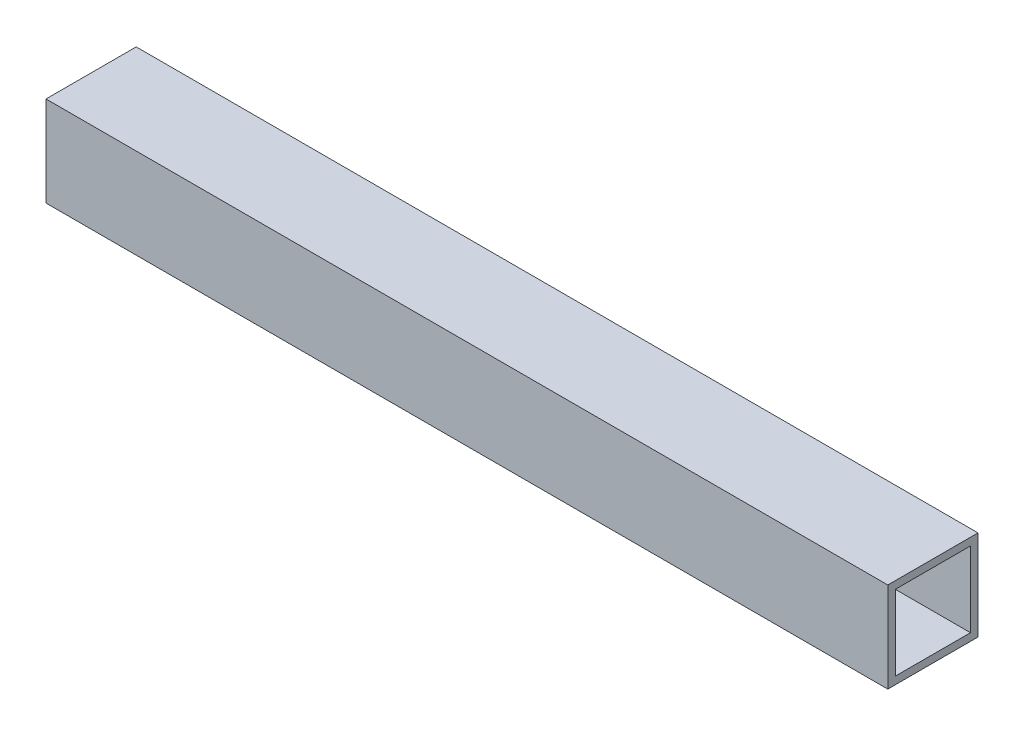
from build123d import *

# Parameters (mm, degrees)
SKETCH1_W           = 19.05
SKETCH1_H           = 19.05
SKETCH1_W_2         = 15.875
SKETCH1_H_2         = 15.875
BOSS_EXTRUDE1_DEPTH = 88.9


with BuildPart() as part:
    # Sketch1 → Boss-Extrude1 (new body, symmetric)
    with BuildSketch(Plane(origin=(0, 0, 0), x_dir=(0, -1, 0), z_dir=(1, 0, 0))):
        Rectangle(SKETCH1_W, SKETCH1_H)
        Rectangle(SKETCH1_W_2, SKETCH1_H_2, mode=Mode.SUBTRACT)
    extrude(amount=BOSS_EXTRUDE1_DEPTH, both=True)


solid = part.part
